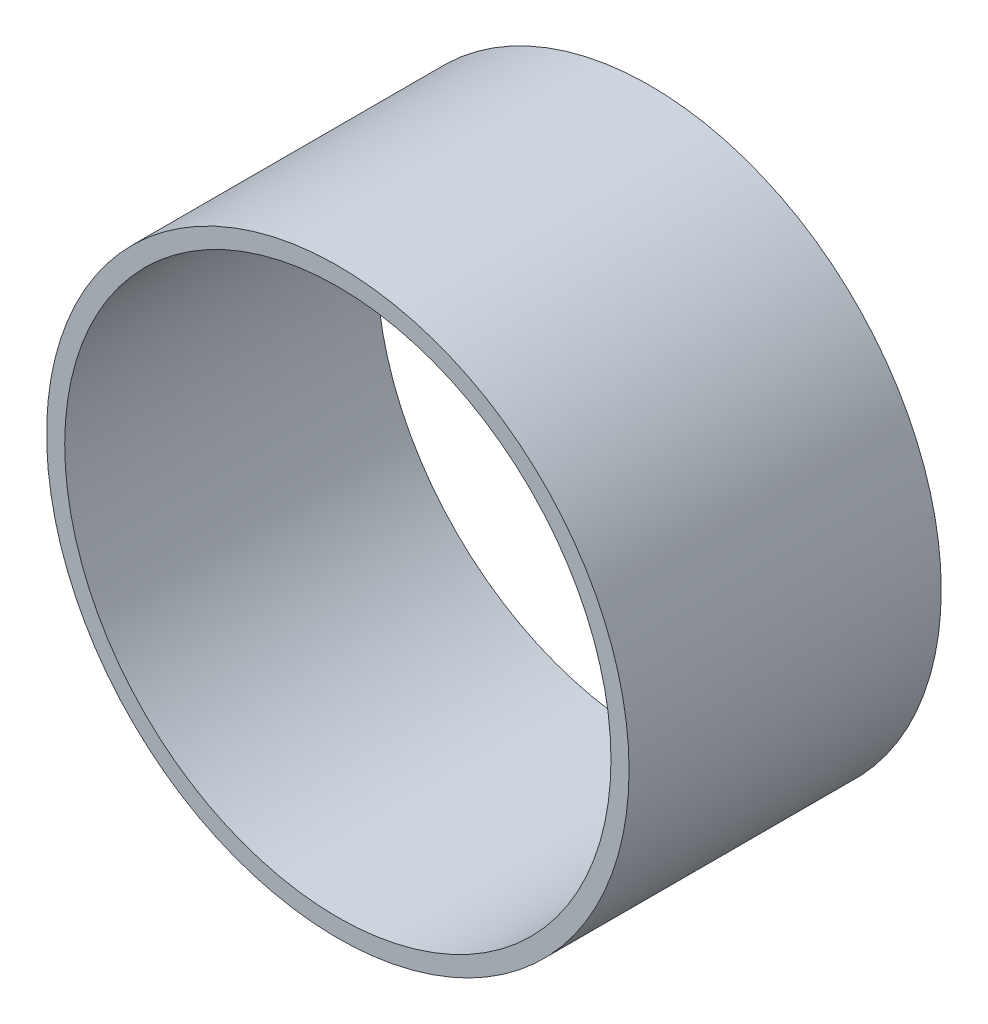
from build123d import *

# Parameters (mm, degrees)
SKETCH1_R          = 23.6982
SKETCH1_R_2        = 22.225
BOSS_EXTRUDE_DEPTH = 25.4


with BuildPart() as part:
    # Sketch1 → Boss-Extrude (new body)
    with BuildSketch(Plane.XY):
        Circle(SKETCH1_R)
        Circle(SKETCH1_R_2, mode=Mode.SUBTRACT)
    extrude(amount=BOSS_EXTRUDE_DEPTH)


solid = part.part
